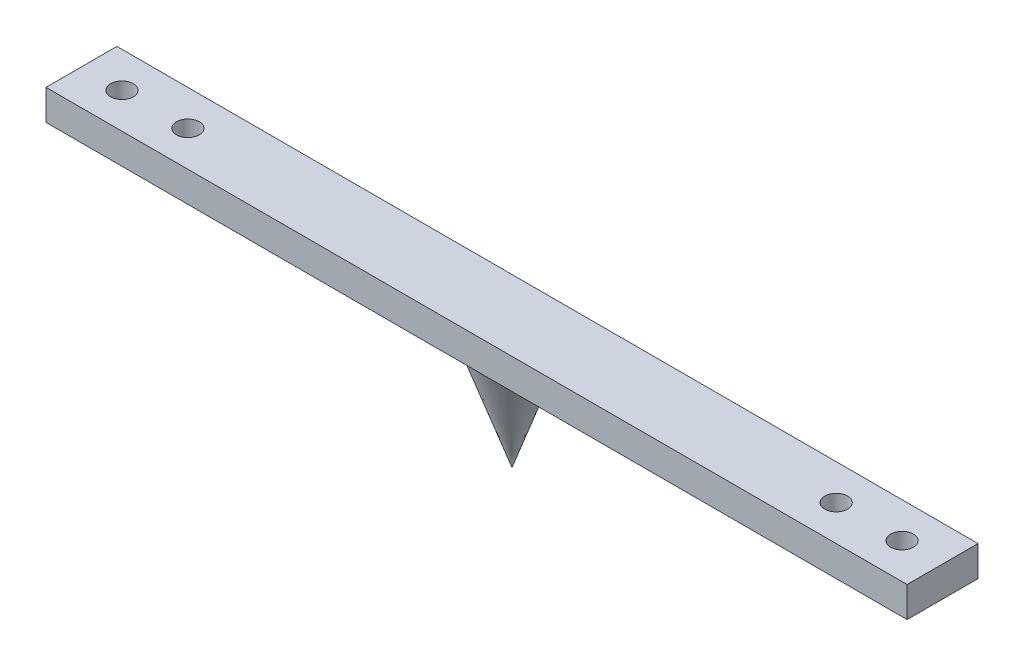
from build123d import *

# Parameters (mm, degrees)
SKIZZE1_W                                           = 170
SKIZZE1_H                                           = 14
AUFSATZ_LINEAR_AUSTRAGEN1_DEPTH                     = 6
STIRNSENKUNG_F_R_M4_SENKSCHRAUBE_KOPF_B_D           = 4.5
STIRNSENKUNG_F_R_M4_SENKSCHRAUBE_KOPF_B_CBORE_D     = 8
STIRNSENKUNG_F_R_M4_SENKSCHRAUBE_KOPF_B_CBORE_DEPTH = 2.2


with BuildPart() as part:
    # Skizze1 → Aufsatz-Linear austragen1 (new body)
    with BuildSketch(Plane(origin=(0, 0, 0), x_dir=(1, 0, 0), z_dir=(0, 1, 0))):
        Rectangle(SKIZZE1_W, SKIZZE1_H)
    extrude(amount=AUFSATZ_LINEAR_AUSTRAGEN1_DEPTH)

    # Stirnsenkung für M4 Senkschraube (Kopf Button)1 (through all)
    with Locations(Plane(origin=(-77, 0, 0), x_dir=(0, 0, -1), z_dir=(0, -1, 0))):
        with Locations((0, 0), (0, 13), (0, 141), (0, 154)):
            CounterBoreHole(STIRNSENKUNG_F_R_M4_SENKSCHRAUBE_KOPF_B_D / 2, STIRNSENKUNG_F_R_M4_SENKSCHRAUBE_KOPF_B_CBORE_D / 2, STIRNSENKUNG_F_R_M4_SENKSCHRAUBE_KOPF_B_CBORE_DEPTH)

    # Skizze3 → Rotation1 (revolve)
    with BuildSketch(Plane.XY):
        Polygon((-7, 0), (0, -20), (0, 0), align=None)
    revolve(axis=Axis((0, 32.961151518, 0), (0, -1, 0)))


solid = part.part
